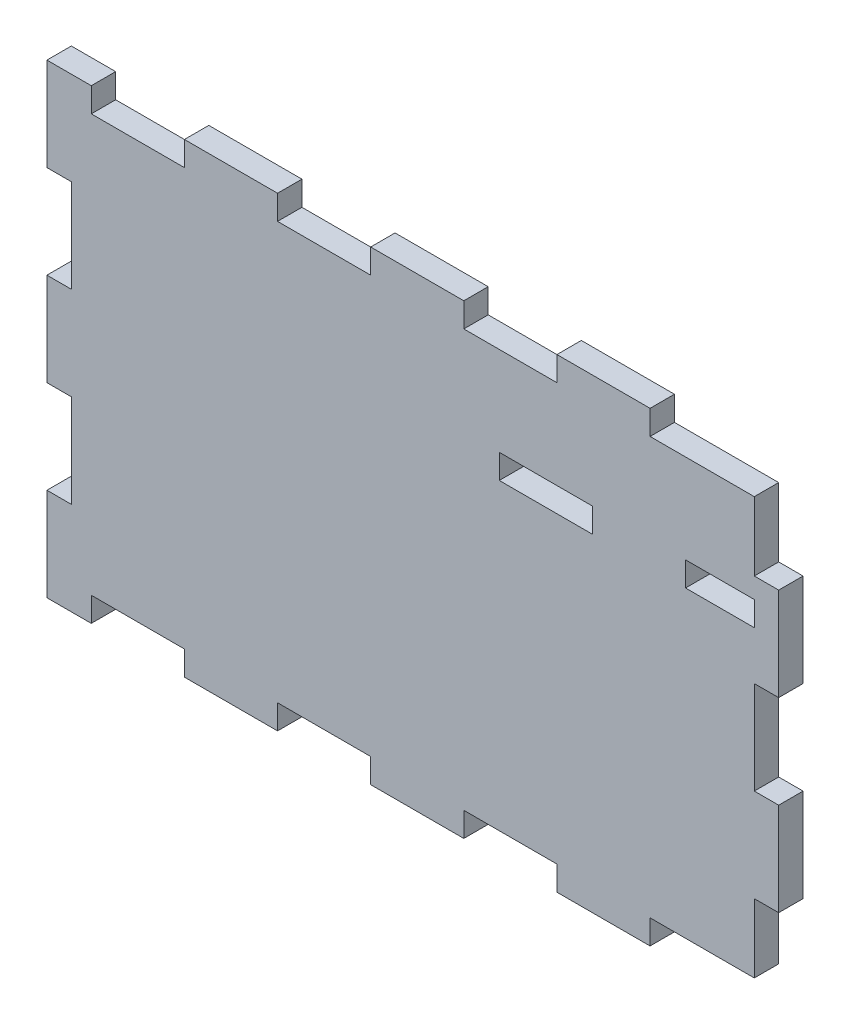
from build123d import *

# Parameters (mm, degrees)
CROQUIS2_W              = 21
CROQUIS2_H              = 5.5
CROQUIS2_W_2            = 15.5
SALIENTE_EXTRUIR1_DEPTH = 5.5
CROQUIS3_W              = 21
CROQUIS3_H              = 5.5
CROQUIS3_W_2            = 7.5
SALIENTE_EXTRUIR2_DEPTH = 2.5
CROQUIS4_W              = 5.5
CROQUIS4_H              = 18.5
CROQUIS4_H_2            = 21
SALIENTE_EXTRUIR3_DEPTH = 2.5
CROQUIS5_W              = 10
CROQUIS5_H              = 5.5
CROQUIS5_W_2            = 21
SALIENTE_EXTRUIR4_DEPTH = 2.5
CROQUIS6_W              = 5.5
CROQUIS6_H              = 21
SALIENTE_EXTRUIR5_DEPTH = 2.5


with BuildPart() as part:
    # Croquis2 → Saliente-Extruir1 (new body)
    with BuildSketch(Plane.XY):
        Polygon((-60.290430527, -48.844252157), (-52.790430527, -48.844252157), (-52.790430527, -45.844252157), (-31.790430527, -45.844252157), (-31.790430527, -48.844252157), (-10.790430527, -48.844252157), (-10.790430527, -45.844252157), (10.209569473, -45.844252157), (10.209569473, -48.844252157), (31.209569473, -48.844252157), (31.209569473, -45.844252157), (52.209569473, -45.844252157), (52.209569473, -48.844252157), (73.209569473, -48.844252157), (73.209569473, -45.844252157), (94.209569473, -45.844252157), (96.709569473, -45.844252157), (96.709569473, -30.344252157), (99.709569473, -30.344252157), (99.709569473, -9.344252157), (96.709569473, -9.344252157), (96.709569473, 11.655747843), (99.709569473, 11.655747843), (99.709569473, 32.655747843), (96.709569473, 32.655747843), (96.709569473, 48.155747843), (73.209569473, 48.155747843), (73.209569473, 51.155747843), (52.209569473, 51.155747843), (52.209569473, 48.155747843), (31.209569473, 48.155747843), (31.209569473, 51.155747843), (10.209569473, 51.155747843), (10.209569473, 48.155747843), (-10.790430527, 48.155747843), (-10.790430527, 51.155747843), (-31.790430527, 51.155747843), (-31.790430527, 48.155747843), (-52.790430527, 48.155747843), (-52.790430527, 51.155747843), (-60.290430527, 51.155747843), (-60.290430527, 32.655747843), (-57.290430527, 32.655747843), (-57.290430527, 11.655747843), (-60.290430527, 11.655747843), (-60.290430527, -9.344252157), (-57.290430527, -9.344252157), (-57.290430527, -30.344252157), (-60.290430527, -30.344252157), align=None)
        with Locations((49.709569473, 25.315747843)):
            Rectangle(CROQUIS2_W, CROQUIS2_H, mode=Mode.SUBTRACT)
        with Locations((88.959569473, 25.315747843)):
            Rectangle(CROQUIS2_W_2, CROQUIS2_H, mode=Mode.SUBTRACT)
    extrude(amount=SALIENTE_EXTRUIR1_DEPTH)

    # Croquis3 → Saliente-Extruir2 (add)
    with BuildSketch(Plane(origin=(0, 51.155747843, 0), x_dir=(1, 0, 0), z_dir=(0, 1, 0))):
        with Locations((62.709569473, -2.75)):
            Rectangle(CROQUIS3_W, CROQUIS3_H)
        with Locations((20.709569473, -2.75)):
            Rectangle(CROQUIS3_W, CROQUIS3_H)
        with Locations((-21.290430527, -2.75)):
            Rectangle(CROQUIS3_W, CROQUIS3_H)
        with Locations((-56.540430527, -2.75)):
            Rectangle(CROQUIS3_W_2, CROQUIS3_H)
    extrude(amount=SALIENTE_EXTRUIR2_DEPTH)

    # Croquis4 → Saliente-Extruir3 (add)
    with BuildSketch(Plane.ZY.offset(60.290430527)):
        with Locations((2.75, -39.594252157)):
            Rectangle(CROQUIS4_W, CROQUIS4_H)
        with Locations((2.75, 1.155747843)):
            Rectangle(CROQUIS4_W, CROQUIS4_H_2)
        with Locations((2.75, 43.155747843)):
            Rectangle(CROQUIS4_W, CROQUIS4_H_2)
    extrude(amount=SALIENTE_EXTRUIR3_DEPTH)

    # Croquis5 → Saliente-Extruir4 (add)
    with BuildSketch(Plane.XZ.offset(48.844252157)):
        with Locations((-57.790430527, 2.75)):
            Rectangle(CROQUIS5_W, CROQUIS5_H)
        with Locations((-21.290430527, 2.75)):
            Rectangle(CROQUIS5_W_2, CROQUIS5_H)
        with Locations((20.709569473, 2.75)):
            Rectangle(CROQUIS5_W_2, CROQUIS5_H)
        with Locations((62.709569473, 2.75)):
            Rectangle(CROQUIS5_W_2, CROQUIS5_H)
    extrude(amount=SALIENTE_EXTRUIR4_DEPTH)

    # Croquis6 → Saliente-Extruir5 (add)
    with BuildSketch(Plane(origin=(99.709569473, 0, 0), x_dir=(0, 0, -1), z_dir=(1, 0, 0))):
        with Locations((-2.75, 22.155747843)):
            Rectangle(CROQUIS6_W, CROQUIS6_H)
        with Locations((-2.75, -19.844252157)):
            Rectangle(CROQUIS6_W, CROQUIS6_H)
    extrude(amount=SALIENTE_EXTRUIR5_DEPTH)


solid = part.part
